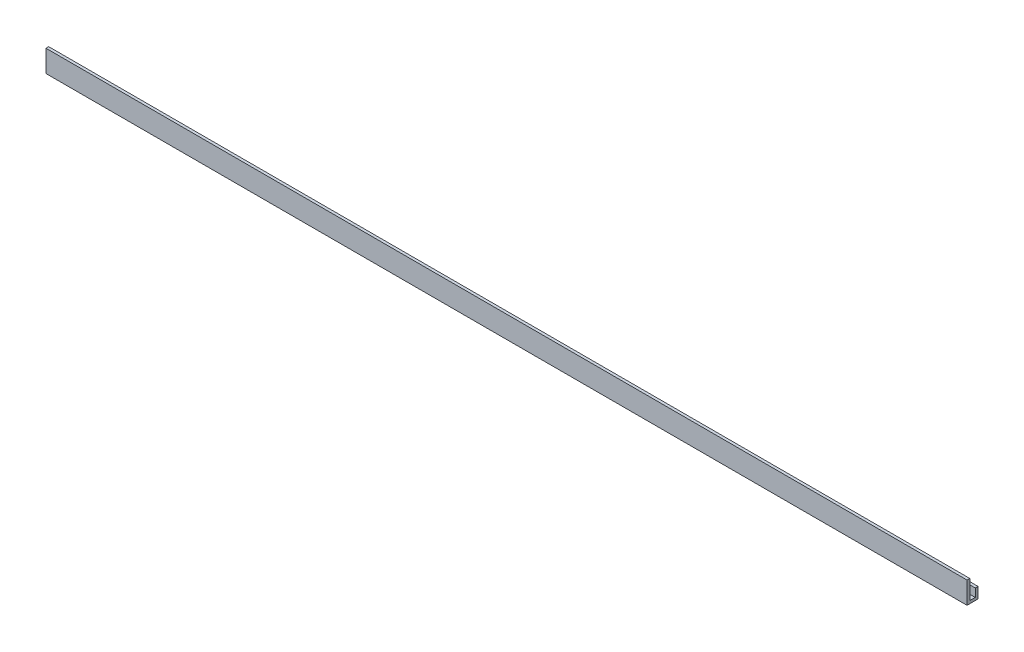
from build123d import *

# Parameters (mm, degrees)
BOSS_EXTRUDE1_DEPTH      = 266.7
BOSS_EXTRUDE1_DEPTH_BACK = 266.7


with BuildPart() as part:
    # Sketch1 → Boss-Extrude1 (new, two sides: drawn at the far end of the back side and taken through both)
    with BuildSketch(Plane(origin=(0, 0, 0), x_dir=(0, 0, -1), z_dir=(1, 0, 0)).offset(-BOSS_EXTRUDE1_DEPTH_BACK)):
        Polygon((0, 0), (0, 11.1125), (-1.5875, 11.1125), (-1.5875, -1.5875), (4.7625, -1.5875), (4.7625, 4.7625), (3.175, 4.7625), (3.175, 0), align=None)
    extrude(amount=BOSS_EXTRUDE1_DEPTH + BOSS_EXTRUDE1_DEPTH_BACK)


solid = part.part
